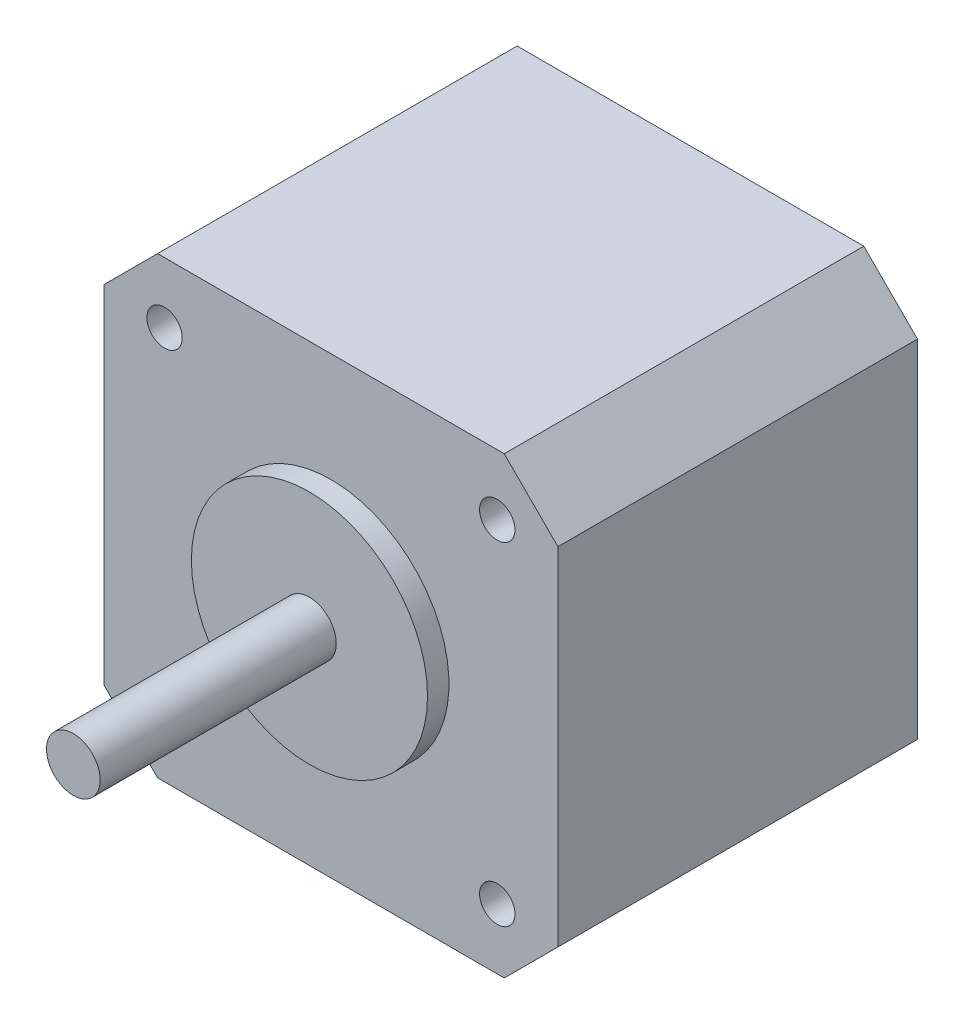
from build123d import *

# Parameters (mm, degrees)
SKETCH1_W                = 42.3
SKETCH1_H                = 42.3
BOSS_EXTRUDE1_DEPTH      = 33.5
SKETCH2_R                = 1.65
CUT_EXTRUDE1_DEPTH       = 10
SKETCH3_R                = 11
BOSS_EXTRUDE2_DEPTH      = 2
SKETCH4_R                = 2.5
BOSS_EXTRUDE3_DEPTH      = 22
BOSS_EXTRUDE3_DEPTH_BACK = 45
SKETCH5_W                = 21.3
SKETCH5_H                = 2.8
BOSS_EXTRUDE4_DEPTH      = 7.15
CHAMFER1_SIZE            = 5


with BuildPart() as part:
    # Sketch1 → Boss-Extrude1 (new body)
    with BuildSketch(Plane.XY):
        with Locations((21.15, 21.15)):
            Rectangle(SKETCH1_W, SKETCH1_H)
    extrude(amount=BOSS_EXTRUDE1_DEPTH)

    # Sketch2 → Cut-Extrude1 (cut)
    with BuildSketch(Plane.XY.offset(33.5)):
        with Locations((5.65, 36.65)):
            Circle(SKETCH2_R)
        with Locations((36.65, 36.65)):
            Circle(SKETCH2_R)
        with Locations((5.65, 5.65)):
            Circle(SKETCH2_R)
        with Locations((36.65, 5.65)):
            Circle(SKETCH2_R)
    extrude(amount=-CUT_EXTRUDE1_DEPTH, mode=Mode.SUBTRACT)

    # Sketch3 → Boss-Extrude2 (add)
    with BuildSketch(Plane.XY.offset(33.5)):
        with Locations((21.15, 21.15)):
            Circle(SKETCH3_R)
    extrude(amount=BOSS_EXTRUDE2_DEPTH)

    # Sketch4 → Boss-Extrude3 (add, two sides)
    with BuildSketch(Plane.XY.offset(35.5)) as boss_extrude3_sk:
        with Locations((21.15, 21.15)):
            Circle(SKETCH4_R)
    extrude(amount=BOSS_EXTRUDE3_DEPTH)
    extrude(boss_extrude3_sk.sketch, amount=-BOSS_EXTRUDE3_DEPTH_BACK)

    # Sketch5 → Boss-Extrude4 (add)
    with BuildSketch(Plane(origin=(0, 0, 0), x_dir=(-1, 0, 0), z_dir=(0, 0, -1))):
        with Locations((-21.15, -1.4)):
            Rectangle(SKETCH5_W, SKETCH5_H)
    extrude(amount=-BOSS_EXTRUDE4_DEPTH)

    # Chamfer1
    chamfer1_edges = [part.edges().sort_by_distance(p)[0] for p in [
        (0, 0, 16.75),
        (42.3, 0, 16.75),
        (42.3, 42.3, 16.75),
        (0, 42.3, 16.75),
    ]]
    chamfer(chamfer1_edges, length=CHAMFER1_SIZE)


solid = part.part
